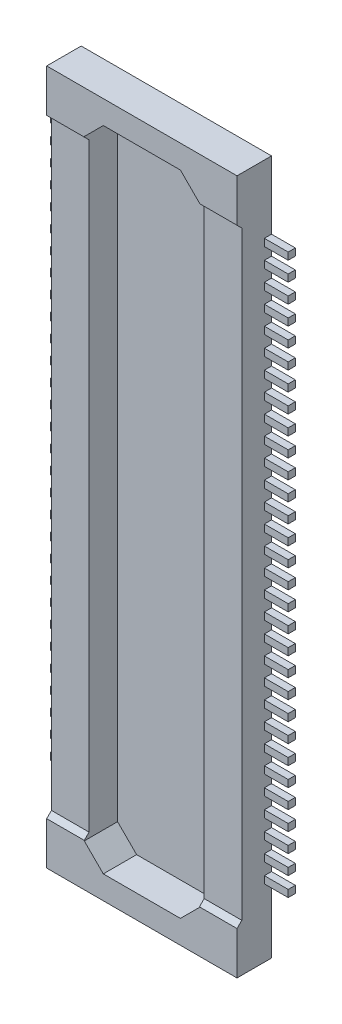
from build123d import *

# Parameters (mm, degrees)
SKETCH1_W                  = 4
SKETCH1_H                  = 14.6
EXTRUDE1_DEPTH             = 0.725
SKETCH2_W                  = 2.42
SKETCH2_H                  = 13.62
CUT_EXTRUDE1_DEPTH         = 0.7
CUT_EXTRUDE2_DEPTH         = 4.21
CUT_EXTRUDE2_DEPTH_BACK    = 1.79
SKETCH29_W                 = 0.15
SKETCH29_H                 = 0.15
EXTRUDE26_DEPTH            = 0.5
CHAMFER1_SIZE              = 0.4
CHAMFER2_SIZE              = 0.4
CHAMFER3_SIZE              = 0.4
CHAMFER4_SIZE              = 0.4
LPATTERN1_COUNT            = 30
LPATTERN1_PITCH            = 0.4
LPATTERN1_COPY_1_SKETCH_W  = 0.15
LPATTERN1_COPY_1_SKETCH_H  = 0.15
LPATTERN1_COPY_1_DEPTH     = 0.5
LPATTERN1_COPY_2_SKETCH_W  = 0.15
LPATTERN1_COPY_2_SKETCH_H  = 0.15
LPATTERN1_COPY_2_DEPTH     = 0.5
LPATTERN1_COPY_3_SKETCH_W  = 0.15
LPATTERN1_COPY_3_SKETCH_H  = 0.15
LPATTERN1_COPY_3_DEPTH     = 0.5
LPATTERN1_COPY_4_SKETCH_W  = 0.15
LPATTERN1_COPY_4_SKETCH_H  = 0.15
LPATTERN1_COPY_4_DEPTH     = 0.5
LPATTERN1_COPY_5_SKETCH_W  = 0.15
LPATTERN1_COPY_5_SKETCH_H  = 0.15
LPATTERN1_COPY_5_DEPTH     = 0.5
LPATTERN1_COPY_6_SKETCH_W  = 0.15
LPATTERN1_COPY_6_SKETCH_H  = 0.15
LPATTERN1_COPY_6_DEPTH     = 0.5
LPATTERN1_COPY_7_SKETCH_W  = 0.15
LPATTERN1_COPY_7_SKETCH_H  = 0.15
LPATTERN1_COPY_7_DEPTH     = 0.5
LPATTERN1_COPY_8_SKETCH_W  = 0.15
LPATTERN1_COPY_8_SKETCH_H  = 0.15
LPATTERN1_COPY_8_DEPTH     = 0.5
LPATTERN1_COPY_9_SKETCH_W  = 0.15
LPATTERN1_COPY_9_SKETCH_H  = 0.15
LPATTERN1_COPY_9_DEPTH     = 0.5
LPATTERN1_COPY_10_SKETCH_W = 0.15
LPATTERN1_COPY_10_SKETCH_H = 0.15
LPATTERN1_COPY_10_DEPTH    = 0.5
LPATTERN1_COPY_11_SKETCH_W = 0.15
LPATTERN1_COPY_11_SKETCH_H = 0.15
LPATTERN1_COPY_11_DEPTH    = 0.5
LPATTERN1_COPY_12_SKETCH_W = 0.15
LPATTERN1_COPY_12_SKETCH_H = 0.15
LPATTERN1_COPY_12_DEPTH    = 0.5
LPATTERN1_COPY_13_SKETCH_W = 0.15
LPATTERN1_COPY_13_SKETCH_H = 0.15
LPATTERN1_COPY_13_DEPTH    = 0.5
LPATTERN1_COPY_14_SKETCH_W = 0.15
LPATTERN1_COPY_14_SKETCH_H = 0.15
LPATTERN1_COPY_14_DEPTH    = 0.5
LPATTERN1_COPY_15_SKETCH_W = 0.15
LPATTERN1_COPY_15_SKETCH_H = 0.15
LPATTERN1_COPY_15_DEPTH    = 0.5
LPATTERN1_COPY_16_SKETCH_W = 0.15
LPATTERN1_COPY_16_SKETCH_H = 0.15
LPATTERN1_COPY_16_DEPTH    = 0.5
LPATTERN1_COPY_17_SKETCH_W = 0.15
LPATTERN1_COPY_17_SKETCH_H = 0.15
LPATTERN1_COPY_17_DEPTH    = 0.5
LPATTERN1_COPY_18_SKETCH_W = 0.15
LPATTERN1_COPY_18_SKETCH_H = 0.15
LPATTERN1_COPY_18_DEPTH    = 0.5
LPATTERN1_COPY_19_SKETCH_W = 0.15
LPATTERN1_COPY_19_SKETCH_H = 0.15
LPATTERN1_COPY_19_DEPTH    = 0.5
LPATTERN1_COPY_20_SKETCH_W = 0.15
LPATTERN1_COPY_20_SKETCH_H = 0.15
LPATTERN1_COPY_20_DEPTH    = 0.5
LPATTERN1_COPY_21_SKETCH_W = 0.15
LPATTERN1_COPY_21_SKETCH_H = 0.15
LPATTERN1_COPY_21_DEPTH    = 0.5
LPATTERN1_COPY_22_SKETCH_W = 0.15
LPATTERN1_COPY_22_SKETCH_H = 0.15
LPATTERN1_COPY_22_DEPTH    = 0.5
LPATTERN1_COPY_23_SKETCH_W = 0.15
LPATTERN1_COPY_23_SKETCH_H = 0.15
LPATTERN1_COPY_23_DEPTH    = 0.5
LPATTERN1_COPY_24_SKETCH_W = 0.15
LPATTERN1_COPY_24_SKETCH_H = 0.15
LPATTERN1_COPY_24_DEPTH    = 0.5
LPATTERN1_COPY_25_SKETCH_W = 0.15
LPATTERN1_COPY_25_SKETCH_H = 0.15
LPATTERN1_COPY_25_DEPTH    = 0.5
LPATTERN1_COPY_26_SKETCH_W = 0.15
LPATTERN1_COPY_26_SKETCH_H = 0.15
LPATTERN1_COPY_26_DEPTH    = 0.5
LPATTERN1_COPY_27_SKETCH_W = 0.15
LPATTERN1_COPY_27_SKETCH_H = 0.15
LPATTERN1_COPY_27_DEPTH    = 0.5
LPATTERN1_COPY_28_SKETCH_W = 0.15
LPATTERN1_COPY_28_SKETCH_H = 0.15
LPATTERN1_COPY_28_DEPTH    = 0.5
LPATTERN1_COPY_29_SKETCH_W = 0.15
LPATTERN1_COPY_29_SKETCH_H = 0.15
LPATTERN1_COPY_29_DEPTH    = 0.5


with BuildPart() as part:
    # Sketch1 → Extrude1 (new body)
    with BuildSketch(Plane(origin=(0, 0, 0), x_dir=(-1, 0, 0), z_dir=(0, 0, -1))):
        Rectangle(SKETCH1_W, SKETCH1_H)
    extrude(amount=-EXTRUDE1_DEPTH)

    # Sketch2 → Cut-Extrude1 (cut)
    with BuildSketch(Plane.XY.offset(0.725)):
        Rectangle(SKETCH2_W, SKETCH2_H)
    extrude(amount=-CUT_EXTRUDE1_DEPTH, mode=Mode.SUBTRACT)

    # Sketch3 → Cut-Extrude2 (cut, two sides)
    with BuildSketch(Plane(origin=(-1.21, 0, 0), x_dir=(0, 0, -1), z_dir=(1, 0, 0))) as cut_extrude2_sk:
        Polygon((-0.725, -6.4), (-0.625, -6.3), (-0.625, 6.3), (-0.725, 6.4), align=None)
    extrude(amount=CUT_EXTRUDE2_DEPTH, mode=Mode.SUBTRACT)
    extrude(cut_extrude2_sk.sketch, amount=-CUT_EXTRUDE2_DEPTH_BACK, mode=Mode.SUBTRACT)

    # Sketch29 → Extrude26 (add)
    with BuildSketch(Plane.ZY.offset(2)):
        with Locations((0.075, 5.8)):
            Rectangle(SKETCH29_W, SKETCH29_H)
    extrude26 = extrude(amount=EXTRUDE26_DEPTH)

    # Mirror1: Extrude26 across plane
    add(extrude26.mirror(Plane(origin=(0, 0, 0), x_dir=(0, 0, 1), z_dir=(1, 0, 0))))

    # Chamfer1
    chamfer1_edges = [part.edges().sort_by_distance(p)[0] for p in [
        (-1.21, -6.81, 0.375),
    ]]
    chamfer(chamfer1_edges, length=CHAMFER1_SIZE)

    # Chamfer2
    chamfer2_edges = [part.edges().sort_by_distance(p)[0] for p in [
        (1.21, -6.81, 0.375),
    ]]
    chamfer(chamfer2_edges, length=CHAMFER2_SIZE)

    # Chamfer3
    chamfer3_edges = [part.edges().sort_by_distance(p)[0] for p in [
        (1.21, 6.81, 0.375),
    ]]
    chamfer(chamfer3_edges, length=CHAMFER3_SIZE)

    # Chamfer4
    chamfer4_edges = [part.edges().sort_by_distance(p)[0] for p in [
        (-1.21, 6.81, 0.375),
    ]]
    chamfer(chamfer4_edges, length=CHAMFER4_SIZE)

    # LPattern1: Extrude26 ×30
    with Locations(*[(0, -i * LPATTERN1_PITCH, 0) for i in range(1, LPATTERN1_COUNT)]):
        add(extrude26)

    # LPattern1 copy 1 sketch → LPattern1 copy 1 (add)
    with BuildSketch(Plane(origin=(2, -0.4, 0), x_dir=(0, 0, 1), z_dir=(1, 0, 0))):
        with Locations((0.075, -5.8)):
            Rectangle(LPATTERN1_COPY_1_SKETCH_W, LPATTERN1_COPY_1_SKETCH_H)
    extrude(amount=LPATTERN1_COPY_1_DEPTH)

    # LPattern1 copy 2 sketch → LPattern1 copy 2 (add)
    with BuildSketch(Plane(origin=(2, -0.8, 0), x_dir=(0, 0, 1), z_dir=(1, 0, 0))):
        with Locations((0.075, -5.8)):
            Rectangle(LPATTERN1_COPY_2_SKETCH_W, LPATTERN1_COPY_2_SKETCH_H)
    extrude(amount=LPATTERN1_COPY_2_DEPTH)

    # LPattern1 copy 3 sketch → LPattern1 copy 3 (add)
    with BuildSketch(Plane(origin=(2, -1.2, 0), x_dir=(0, 0, 1), z_dir=(1, 0, 0))):
        with Locations((0.075, -5.8)):
            Rectangle(LPATTERN1_COPY_3_SKETCH_W, LPATTERN1_COPY_3_SKETCH_H)
    extrude(amount=LPATTERN1_COPY_3_DEPTH)

    # LPattern1 copy 4 sketch → LPattern1 copy 4 (add)
    with BuildSketch(Plane(origin=(2, -1.6, 0), x_dir=(0, 0, 1), z_dir=(1, 0, 0))):
        with Locations((0.075, -5.8)):
            Rectangle(LPATTERN1_COPY_4_SKETCH_W, LPATTERN1_COPY_4_SKETCH_H)
    extrude(amount=LPATTERN1_COPY_4_DEPTH)

    # LPattern1 copy 5 sketch → LPattern1 copy 5 (add)
    with BuildSketch(Plane(origin=(2, -2, 0), x_dir=(0, 0, 1), z_dir=(1, 0, 0))):
        with Locations((0.075, -5.8)):
            Rectangle(LPATTERN1_COPY_5_SKETCH_W, LPATTERN1_COPY_5_SKETCH_H)
    extrude(amount=LPATTERN1_COPY_5_DEPTH)

    # LPattern1 copy 6 sketch → LPattern1 copy 6 (add)
    with BuildSketch(Plane(origin=(2, -2.4, 0), x_dir=(0, 0, 1), z_dir=(1, 0, 0))):
        with Locations((0.075, -5.8)):
            Rectangle(LPATTERN1_COPY_6_SKETCH_W, LPATTERN1_COPY_6_SKETCH_H)
    extrude(amount=LPATTERN1_COPY_6_DEPTH)

    # LPattern1 copy 7 sketch → LPattern1 copy 7 (add)
    with BuildSketch(Plane(origin=(2, -2.8, 0), x_dir=(0, 0, 1), z_dir=(1, 0, 0))):
        with Locations((0.075, -5.8)):
            Rectangle(LPATTERN1_COPY_7_SKETCH_W, LPATTERN1_COPY_7_SKETCH_H)
    extrude(amount=LPATTERN1_COPY_7_DEPTH)

    # LPattern1 copy 8 sketch → LPattern1 copy 8 (add)
    with BuildSketch(Plane(origin=(2, -3.2, 0), x_dir=(0, 0, 1), z_dir=(1, 0, 0))):
        with Locations((0.075, -5.8)):
            Rectangle(LPATTERN1_COPY_8_SKETCH_W, LPATTERN1_COPY_8_SKETCH_H)
    extrude(amount=LPATTERN1_COPY_8_DEPTH)

    # LPattern1 copy 9 sketch → LPattern1 copy 9 (add)
    with BuildSketch(Plane(origin=(2, -3.6, 0), x_dir=(0, 0, 1), z_dir=(1, 0, 0))):
        with Locations((0.075, -5.8)):
            Rectangle(LPATTERN1_COPY_9_SKETCH_W, LPATTERN1_COPY_9_SKETCH_H)
    extrude(amount=LPATTERN1_COPY_9_DEPTH)

    # LPattern1 copy 10 sketch → LPattern1 copy 10 (add)
    with BuildSketch(Plane(origin=(2, -4, 0), x_dir=(0, 0, 1), z_dir=(1, 0, 0))):
        with Locations((0.075, -5.8)):
            Rectangle(LPATTERN1_COPY_10_SKETCH_W, LPATTERN1_COPY_10_SKETCH_H)
    extrude(amount=LPATTERN1_COPY_10_DEPTH)

    # LPattern1 copy 11 sketch → LPattern1 copy 11 (add)
    with BuildSketch(Plane(origin=(2, -4.4, 0), x_dir=(0, 0, 1), z_dir=(1, 0, 0))):
        with Locations((0.075, -5.8)):
            Rectangle(LPATTERN1_COPY_11_SKETCH_W, LPATTERN1_COPY_11_SKETCH_H)
    extrude(amount=LPATTERN1_COPY_11_DEPTH)

    # LPattern1 copy 12 sketch → LPattern1 copy 12 (add)
    with BuildSketch(Plane(origin=(2, -4.8, 0), x_dir=(0, 0, 1), z_dir=(1, 0, 0))):
        with Locations((0.075, -5.8)):
            Rectangle(LPATTERN1_COPY_12_SKETCH_W, LPATTERN1_COPY_12_SKETCH_H)
    extrude(amount=LPATTERN1_COPY_12_DEPTH)

    # LPattern1 copy 13 sketch → LPattern1 copy 13 (add)
    with BuildSketch(Plane(origin=(2, -5.2, 0), x_dir=(0, 0, 1), z_dir=(1, 0, 0))):
        with Locations((0.075, -5.8)):
            Rectangle(LPATTERN1_COPY_13_SKETCH_W, LPATTERN1_COPY_13_SKETCH_H)
    extrude(amount=LPATTERN1_COPY_13_DEPTH)

    # LPattern1 copy 14 sketch → LPattern1 copy 14 (add)
    with BuildSketch(Plane(origin=(2, -5.6, 0), x_dir=(0, 0, 1), z_dir=(1, 0, 0))):
        with Locations((0.075, -5.8)):
            Rectangle(LPATTERN1_COPY_14_SKETCH_W, LPATTERN1_COPY_14_SKETCH_H)
    extrude(amount=LPATTERN1_COPY_14_DEPTH)

    # LPattern1 copy 15 sketch → LPattern1 copy 15 (add)
    with BuildSketch(Plane(origin=(2, -6, 0), x_dir=(0, 0, 1), z_dir=(1, 0, 0))):
        with Locations((0.075, -5.8)):
            Rectangle(LPATTERN1_COPY_15_SKETCH_W, LPATTERN1_COPY_15_SKETCH_H)
    extrude(amount=LPATTERN1_COPY_15_DEPTH)

    # LPattern1 copy 16 sketch → LPattern1 copy 16 (add)
    with BuildSketch(Plane(origin=(2, -6.4, 0), x_dir=(0, 0, 1), z_dir=(1, 0, 0))):
        with Locations((0.075, -5.8)):
            Rectangle(LPATTERN1_COPY_16_SKETCH_W, LPATTERN1_COPY_16_SKETCH_H)
    extrude(amount=LPATTERN1_COPY_16_DEPTH)

    # LPattern1 copy 17 sketch → LPattern1 copy 17 (add)
    with BuildSketch(Plane(origin=(2, -6.8, 0), x_dir=(0, 0, 1), z_dir=(1, 0, 0))):
        with Locations((0.075, -5.8)):
            Rectangle(LPATTERN1_COPY_17_SKETCH_W, LPATTERN1_COPY_17_SKETCH_H)
    extrude(amount=LPATTERN1_COPY_17_DEPTH)

    # LPattern1 copy 18 sketch → LPattern1 copy 18 (add)
    with BuildSketch(Plane(origin=(2, -7.2, 0), x_dir=(0, 0, 1), z_dir=(1, 0, 0))):
        with Locations((0.075, -5.8)):
            Rectangle(LPATTERN1_COPY_18_SKETCH_W, LPATTERN1_COPY_18_SKETCH_H)
    extrude(amount=LPATTERN1_COPY_18_DEPTH)

    # LPattern1 copy 19 sketch → LPattern1 copy 19 (add)
    with BuildSketch(Plane(origin=(2, -7.6, 0), x_dir=(0, 0, 1), z_dir=(1, 0, 0))):
        with Locations((0.075, -5.8)):
            Rectangle(LPATTERN1_COPY_19_SKETCH_W, LPATTERN1_COPY_19_SKETCH_H)
    extrude(amount=LPATTERN1_COPY_19_DEPTH)

    # LPattern1 copy 20 sketch → LPattern1 copy 20 (add)
    with BuildSketch(Plane(origin=(2, -8, 0), x_dir=(0, 0, 1), z_dir=(1, 0, 0))):
        with Locations((0.075, -5.8)):
            Rectangle(LPATTERN1_COPY_20_SKETCH_W, LPATTERN1_COPY_20_SKETCH_H)
    extrude(amount=LPATTERN1_COPY_20_DEPTH)

    # LPattern1 copy 21 sketch → LPattern1 copy 21 (add)
    with BuildSketch(Plane(origin=(2, -8.4, 0), x_dir=(0, 0, 1), z_dir=(1, 0, 0))):
        with Locations((0.075, -5.8)):
            Rectangle(LPATTERN1_COPY_21_SKETCH_W, LPATTERN1_COPY_21_SKETCH_H)
    extrude(amount=LPATTERN1_COPY_21_DEPTH)

    # LPattern1 copy 22 sketch → LPattern1 copy 22 (add)
    with BuildSketch(Plane(origin=(2, -8.8, 0), x_dir=(0, 0, 1), z_dir=(1, 0, 0))):
        with Locations((0.075, -5.8)):
            Rectangle(LPATTERN1_COPY_22_SKETCH_W, LPATTERN1_COPY_22_SKETCH_H)
    extrude(amount=LPATTERN1_COPY_22_DEPTH)

    # LPattern1 copy 23 sketch → LPattern1 copy 23 (add)
    with BuildSketch(Plane(origin=(2, -9.2, 0), x_dir=(0, 0, 1), z_dir=(1, 0, 0))):
        with Locations((0.075, -5.8)):
            Rectangle(LPATTERN1_COPY_23_SKETCH_W, LPATTERN1_COPY_23_SKETCH_H)
    extrude(amount=LPATTERN1_COPY_23_DEPTH)

    # LPattern1 copy 24 sketch → LPattern1 copy 24 (add)
    with BuildSketch(Plane(origin=(2, -9.6, 0), x_dir=(0, 0, 1), z_dir=(1, 0, 0))):
        with Locations((0.075, -5.8)):
            Rectangle(LPATTERN1_COPY_24_SKETCH_W, LPATTERN1_COPY_24_SKETCH_H)
    extrude(amount=LPATTERN1_COPY_24_DEPTH)

    # LPattern1 copy 25 sketch → LPattern1 copy 25 (add)
    with BuildSketch(Plane(origin=(2, -10, 0), x_dir=(0, 0, 1), z_dir=(1, 0, 0))):
        with Locations((0.075, -5.8)):
            Rectangle(LPATTERN1_COPY_25_SKETCH_W, LPATTERN1_COPY_25_SKETCH_H)
    extrude(amount=LPATTERN1_COPY_25_DEPTH)

    # LPattern1 copy 26 sketch → LPattern1 copy 26 (add)
    with BuildSketch(Plane(origin=(2, -10.4, 0), x_dir=(0, 0, 1), z_dir=(1, 0, 0))):
        with Locations((0.075, -5.8)):
            Rectangle(LPATTERN1_COPY_26_SKETCH_W, LPATTERN1_COPY_26_SKETCH_H)
    extrude(amount=LPATTERN1_COPY_26_DEPTH)

    # LPattern1 copy 27 sketch → LPattern1 copy 27 (add)
    with BuildSketch(Plane(origin=(2, -10.8, 0), x_dir=(0, 0, 1), z_dir=(1, 0, 0))):
        with Locations((0.075, -5.8)):
            Rectangle(LPATTERN1_COPY_27_SKETCH_W, LPATTERN1_COPY_27_SKETCH_H)
    extrude(amount=LPATTERN1_COPY_27_DEPTH)

    # LPattern1 copy 28 sketch → LPattern1 copy 28 (add)
    with BuildSketch(Plane(origin=(2, -11.2, 0), x_dir=(0, 0, 1), z_dir=(1, 0, 0))):
        with Locations((0.075, -5.8)):
            Rectangle(LPATTERN1_COPY_28_SKETCH_W, LPATTERN1_COPY_28_SKETCH_H)
    extrude(amount=LPATTERN1_COPY_28_DEPTH)

    # LPattern1 copy 29 sketch → LPattern1 copy 29 (add)
    with BuildSketch(Plane(origin=(2, -11.6, 0), x_dir=(0, 0, 1), z_dir=(1, 0, 0))):
        with Locations((0.075, -5.8)):
            Rectangle(LPATTERN1_COPY_29_SKETCH_W, LPATTERN1_COPY_29_SKETCH_H)
    extrude(amount=LPATTERN1_COPY_29_DEPTH)


solid = part.part
